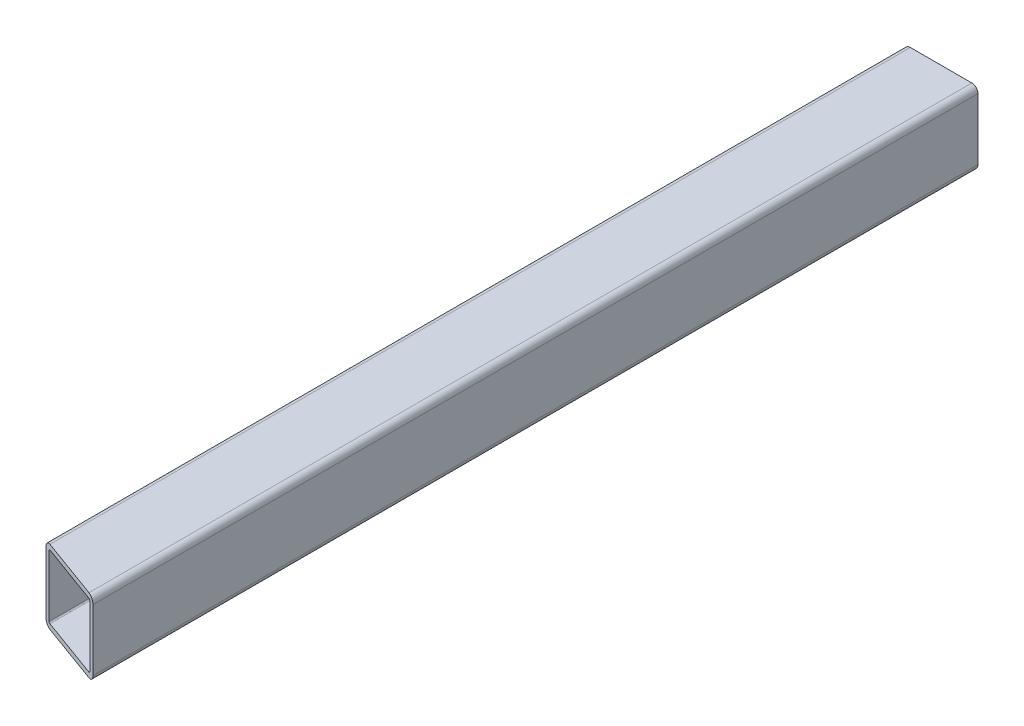
from build123d import *

# Parameters (mm, degrees)
EXTRUDE_THIN1_DEPTH     = 228.6
CUT_EXTRUDE1_DEPTH      = 1
CUT_EXTRUDE1_DEPTH_BACK = 39.1


with BuildPart() as part:
    # Sketch1 → Extrude-Thin1 (new body, symmetric)
    with BuildSketch(Plane.XY):
        with BuildLine():
            Line((-15.875, 19.05), (15.875, 19.05))
            ThreePointArc((15.875, 19.05), (18.12006403, 18.12006403), (19.05, 15.875))
            Line((19.05, 15.875), (19.05, -15.875))
            ThreePointArc((19.05, -15.875), (18.12006403, -18.12006403), (15.875, -19.05))
            Line((15.875, -19.05), (-15.875, -19.05))
            ThreePointArc((-15.875, -19.05), (-18.12006403, -18.12006403), (-19.05, -15.875))
            Line((-19.05, -15.875), (-19.05, 15.875))
            ThreePointArc((-19.05, 15.875), (-18.12006403, 18.12006403), (-15.875, 19.05))
        make_face()
        with BuildLine():
            Line((-15.875, 16.51), (15.875, 16.51))
            ThreePointArc((15.875, 16.51), (16.324012806, 16.324012806), (16.51, 15.875))
            Line((16.51, 15.875), (16.51, -15.875))
            ThreePointArc((16.51, -15.875), (16.324012806, -16.324012806), (15.875, -16.51))
            Line((15.875, -16.51), (-15.875, -16.51))
            ThreePointArc((-15.875, -16.51), (-16.324012806, -16.324012806), (-16.51, -15.875))
            Line((-16.51, -15.875), (-16.51, 15.875))
            ThreePointArc((-16.51, 15.875), (-16.324012806, 16.324012806), (-15.875, 16.51))
        make_face(mode=Mode.SUBTRACT)
    extrude(amount=EXTRUDE_THIN1_DEPTH, both=True)

    # Sketch3 → Cut-Extrude1 (cut, two sides)
    with BuildSketch(Plane(origin=(0, 19.05, 0), x_dir=(1, 0, 0), z_dir=(0, 1, 0))) as cut_extrude1_sk:
        Polygon((890.680220904, -545.847455696), (19.05, -228.6), (-19.05, -214.732734074), (-890.680220904, 102.514721621), (-1525.175132295, -1640.745720186), (256.185309512, -2289.107897503), align=None)
    extrude(amount=CUT_EXTRUDE1_DEPTH, mode=Mode.SUBTRACT)
    extrude(cut_extrude1_sk.sketch, amount=-CUT_EXTRUDE1_DEPTH_BACK, mode=Mode.SUBTRACT)


solid = part.part
